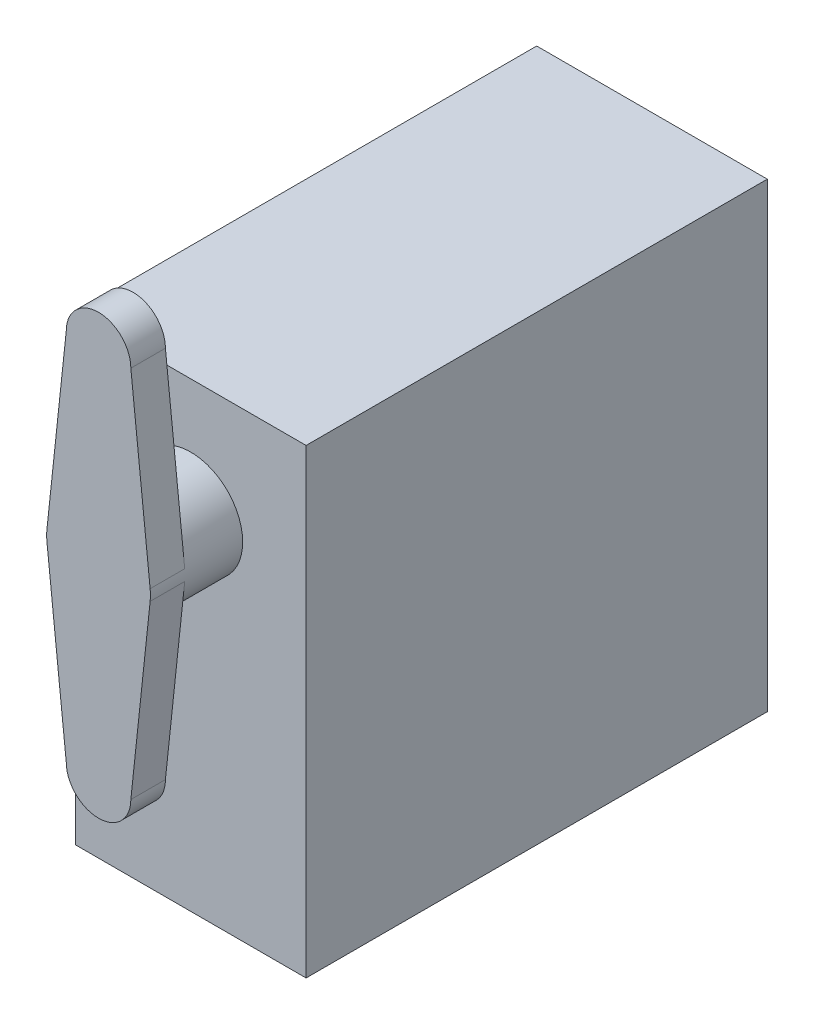
from build123d import *

# Parameters (mm, degrees)
SKETCH2_W           = 20
SKETCH2_H           = 40
BOSS_EXTRUDE1_DEPTH = 40
SKETCH3_R           = 4.5
BOSS_EXTRUDE2_DEPTH = 5
BOSS_EXTRUDE3_DEPTH = 3


with BuildPart() as part:
    # Sketch2 → Boss-Extrude1 (new body)
    with BuildSketch(Plane.XY):
        Rectangle(SKETCH2_W, SKETCH2_H)
    extrude(amount=BOSS_EXTRUDE1_DEPTH)

    # Sketch3 → Boss-Extrude2 (add)
    with BuildSketch(Plane.XY.offset(40)):
        with Locations((0, 10)):
            Circle(SKETCH3_R)
    extrude(amount=BOSS_EXTRUDE2_DEPTH)

    # Sketch5 → Boss-Extrude3 (add)
    with BuildSketch(Plane.XY.offset(45)):
        with BuildLine():
            Line((4.474691, 9.523403), (2.8, -6.2))
            ThreePointArc((2.8, -6.2), (0, -9), (-2.8, -6.2))
            Line((-2.8, -6.2), (-4.474691, 9.523403))
            ThreePointArc((-4.474691, 9.523403), (-4.5, 10), (-4.474691, 10.476597))
            Line((-4.474691, 10.476597), (-2.8, 26.2))
            ThreePointArc((-2.8, 26.2), (0, 29), (2.8, 26.2))
            Line((2.8, 26.2), (4.474691, 10.476597))
            ThreePointArc((4.474691, 10.476597), (4.5, 10), (4.474691, 9.523403))
        make_face()
    extrude(amount=BOSS_EXTRUDE3_DEPTH)


solid = part.part
